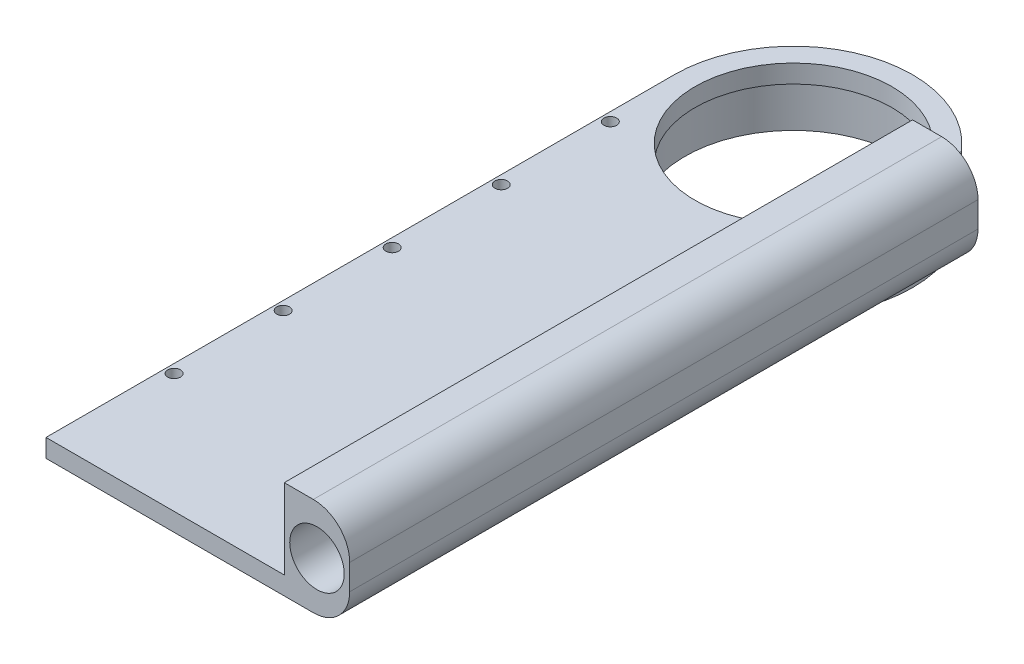
from build123d import *

# Parameters (mm, degrees)
SKETCH1_R            = 2.75
SKETCH1_R_2          = 1.25
SKETCH1_R_3          = 1.75
SKETCH1_R_4          = 4.5
BOSS_EXTRUDE10_DEPTH = 5
SKETCH1_16_R         = 1.25
BOSS_EXTRUDE11_DEPTH = 5
SKETCH3_R            = 1.75
CUT_EXTRUDE5_DEPTH   = 17
CUT_EXTRUDE7_DEPTH   = 10
SKETCH1_18_R         = 4.5
SKETCH1_18_R_2       = 1.75
BOSS_EXTRUDE12_DEPTH = 5
SKETCH10_R           = 32.76798012
SKETCH10_R_2         = 29.85
BOSS_EXTRUDE13_DEPTH = 13
SKETCH11_R           = 27.095
CUT_EXTRUDE8_DEPTH   = 13
BOSS_EXTRUDE14_DEPTH = 3
SKETCH13_W           = 12
SKETCH13_H           = 4
BOSS_EXTRUDE15_DEPTH = 25
SKETCH14_R           = 1.25
CUT_EXTRUDE9_DEPTH   = 25
FILLET1_R            = 2.5
SKETCH18_W           = 172.850535033
SKETCH18_H           = 5
BOSS_EXTRUDE18_DEPTH = 18
SKETCH19_W           = 18
SKETCH19_H           = 172.850535033
BOSS_EXTRUDE19_DEPTH = 22
SKETCH20_R           = 7.5
CUT_EXTRUDE11_DEPTH  = 208
FILLET3_R            = 10


with BuildPart() as part:
    # Sketch1 → Boss-Extrude10 (new body)
    with BuildSketch(Plane(origin=(0, 0, 0), x_dir=(1, 0, 0), z_dir=(0, 1, 0))):
        with BuildLine():
            Line((-32.774, 177.619546288), (-32.774, -22.380453712))
            ThreePointArc((-32.774, -22.380453712), (0, -55.154453712), (32.774, -22.380453712))
            Line((32.774, -22.380453712), (32.774, 177.619546288))
            ThreePointArc((32.774, 177.619546288), (0, 210.393546288), (-32.774, 177.619546288))
        make_face()
        with Locations((-11.258330249, -28.880453712)):
            Circle(SKETCH1_R, mode=Mode.SUBTRACT)
        with Locations((-11.258330249, -15.880453712)):
            Circle(SKETCH1_R, mode=Mode.SUBTRACT)
        with Locations((-6.733414, 27.619546288)):
            Circle(SKETCH1_R_2, mode=Mode.SUBTRACT)
        with Locations((-6.733414, 37.119546288)):
            Circle(SKETCH1_R_2, mode=Mode.SUBTRACT)
        with Locations((-14.032659813, 67.637846288)):
            Circle(SKETCH1_R_3, mode=Mode.SUBTRACT)
        with Locations((0, -35.380453712)):
            Circle(SKETCH1_R, mode=Mode.SUBTRACT)
        with Locations((11.258330249, -28.880453712)):
            Circle(SKETCH1_R, mode=Mode.SUBTRACT)
        with Locations((0, -9.380453712)):
            Circle(SKETCH1_R, mode=Mode.SUBTRACT)
        with Locations((11.258330249, -15.880453712)):
            Circle(SKETCH1_R, mode=Mode.SUBTRACT)
        with Locations((0, 53.605186475)):
            Circle(SKETCH1_R_3, mode=Mode.SUBTRACT)
        with Locations((14.032659813, 67.637846288)):
            Circle(SKETCH1_R_3, mode=Mode.SUBTRACT)
        with Locations((0, 81.6705061)):
            Circle(SKETCH1_R_3, mode=Mode.SUBTRACT)
        with Locations((0, 177.619546288)):
            Circle(SKETCH1_R_4, mode=Mode.SUBTRACT)
        with Locations((0, 67.637846288)):
            Circle(SKETCH1_R_4, mode=Mode.SUBTRACT)
    extrude(amount=-BOSS_EXTRUDE10_DEPTH)

    # Sketch1_16 → Boss-Extrude11 (add)
    with BuildSketch(Plane(origin=(0, 0, 0), x_dir=(1, 0, 0), z_dir=(0, 1, 0))):
        with Locations((-6.733414, 37.119546288)):
            Circle(SKETCH1_16_R)
        with Locations((-6.733414, 27.619546288)):
            Circle(SKETCH1_16_R)
    extrude(amount=-BOSS_EXTRUDE11_DEPTH)

    # Sketch3 → Cut-Extrude5 (cut)
    with BuildSketch(Plane.XZ.offset(5)):
        with Locations((15, -102.056321071)):
            Circle(SKETCH3_R)
        with Locations((-30.384, -67.619546288)):
            Circle(SKETCH3_R)
        with Locations((-30.384, -37.619546288)):
            Circle(SKETCH3_R)
        with Locations((-30.384, -97.619546288)):
            Circle(SKETCH3_R)
        with Locations((-30.384, -127.619546288)):
            Circle(SKETCH3_R)
        with Locations((-30.384, -157.619546288)):
            Circle(SKETCH3_R)
        with Locations((30.384, -157.619546288)):
            Circle(SKETCH3_R)
        with Locations((30.384, -127.619546288)):
            Circle(SKETCH3_R)
        with Locations((30.384, -97.619546288)):
            Circle(SKETCH3_R)
        with Locations((30.384, -67.619546288)):
            Circle(SKETCH3_R)
        with Locations((30.384, -37.619546288)):
            Circle(SKETCH3_R)
    extrude(amount=-CUT_EXTRUDE5_DEPTH, mode=Mode.SUBTRACT)

    # Sketch2 → Cut-Extrude7 (cut)
    with BuildSketch(Plane.XZ):
        with BuildLine():
            Line((-32.774000001, -4.769011255), (32.774000001, -4.769011255))
            Line((32.774000001, -4.769011255), (32.774000001, 22.380453712))
            ThreePointArc((32.774000001, 22.380453712), (0, 55.154453713), (-32.774000001, 22.380453712))
            Line((-32.774000001, 22.380453712), (-32.774000001, -4.769011255))
        make_face()
    extrude(amount=CUT_EXTRUDE7_DEPTH, mode=Mode.SUBTRACT)

    # Sketch1_18 → Boss-Extrude12 (add)
    with BuildSketch(Plane(origin=(0, 0, 0), x_dir=(1, 0, 0), z_dir=(0, 1, 0))):
        with Locations((0, 67.637846288)):
            Circle(SKETCH1_18_R)
        with Locations((0, 53.605186475)):
            Circle(SKETCH1_18_R_2)
        with Locations((-14.032659813, 67.637846288)):
            Circle(SKETCH1_18_R_2)
        with Locations((0, 81.6705061)):
            Circle(SKETCH1_18_R_2)
        with Locations((14.032659813, 67.637846288)):
            Circle(SKETCH1_18_R_2)
    extrude(amount=-BOSS_EXTRUDE12_DEPTH)

    # Sketch10 → Boss-Extrude13 (add)
    with BuildSketch(Plane.XZ.offset(5)):
        with Locations((0, -177.619546288)):
            Circle(SKETCH10_R)
        with Locations((0, -177.619546288)):
            Circle(SKETCH10_R_2, mode=Mode.SUBTRACT)
    extrude(amount=BOSS_EXTRUDE13_DEPTH)

    # Sketch11 → Cut-Extrude8 (cut)
    with BuildSketch(Plane.XZ.offset(5)):
        with Locations((0, -177.619546288)):
            Circle(SKETCH11_R)
    extrude(amount=-CUT_EXTRUDE8_DEPTH, mode=Mode.SUBTRACT)

    # Sketch5 → Boss-Extrude14 (add)
    with BuildSketch(Plane.XZ.offset(5)):
        Polygon((-7.824000001, -54.439091018), (-7.824000001, -50.294800153), (11.225999999, -50.294800153), (11.225999999, -52.737107845), (-5.625923078, -52.737107845), (-5.625923078, -55.667877076), align=None)
        Polygon((-7.824000001, -77.404415537), (-7.824000001, -74.946843422), (6.78786899, -68.867786932), (-7.824000001, -62.792546547), (-7.824000001, -60.308261691), (11.225999999, -68.478544143), (11.225999999, -69.260845826), align=None)
        Polygon((11.225999999, -103.048646307), (-7.824000001, -103.048646307), (-7.824000001, -102.144229239), (6.650489182, -90.592877076), (-7.824000001, -90.592877076), (-7.824000001, -88.150569384), (11.225999999, -88.150569384), (11.225999999, -89.150389095), (-3.210328126, -100.606338614), (11.225999999, -100.606338614), align=None)
        with BuildLine():
            Line((-7.824000001, -110.131338614), (-7.824000001, -107.689030922))
            Line((-7.824000001, -107.689030922), (4.963770432, -107.689030922))
            add(Edge.make_bspline(
                [(4.963770432, -107.689030922), (5.195284298, -107.690885051), (5.64058499, -107.694451338), (6.282127583, -107.710622767), (6.869902619, -107.750196634), (7.404321802, -107.799507581), (7.886610584, -107.856591103), (8.313879678, -107.93850968), (8.689949893, -108.026630447), (9.116491069, -108.169153007), (9.595339884, -108.393934907), (10.111712604, -108.751940741), (10.571673312, -109.196571131), (10.907530608, -109.628416016), (11.13794534, -110.012545465), (11.297510075, -110.317623544), (11.424793799, -110.643597173), (11.533834774, -110.983321068), (11.610882457, -111.340471014), (11.674764914, -111.711796449), (11.707736212, -112.10111909), (11.712193771, -112.36625392), (11.714461538, -112.501140297)],
                knots=[0, 0, 0, 0, 1.452629871, 2.794031722, 4.025694375, 5.147841271, 6.161522649, 7.070971626, 7.876222586, 8.582890533, 9.889534196, 11.180212824, 12.506716644, 13.889181747, 14.598189363, 15.315636514, 16.046279605, 16.790911698, 17.551832231, 18.336450274, 19.153675152, 20, 20, 20, 20], degree=3))
            add(Edge.make_bspline(
                [(11.714461538, -112.501140297), (11.709715065, -112.690996015), (11.700270364, -113.068777754), (11.611584234, -113.632488096), (11.470780234, -114.18810384), (11.271570837, -114.74809611), (10.996525721, -115.32564021), (10.608190367, -115.923011587), (10.131794371, -116.566713359), (9.758962639, -116.990402865), (9.562177884, -117.214030922)],
                knots=[0, 0, 0, 0, 0.856972921, 1.705235559, 2.570545082, 3.44278821, 4.385852251, 5.452194716, 6.655239899, 8, 8, 8, 8], degree=3))
            Line((9.562177884, -117.214030922), (7.80676923, -116.004325393))
            add(Edge.make_bspline(
                [(7.80676923, -116.004325393), (7.894907738, -115.863356861), (8.065044953, -115.59123978), (8.304537659, -115.195035974), (8.521847451, -114.828568699), (8.718040268, -114.494300424), (8.884251955, -114.186630498), (9.035266134, -113.914342494), (9.157620565, -113.667523035), (9.230416916, -113.512520303), (9.264521634, -113.439902316)],
                knots=[0, 0, 0, 0, 1.35182785, 2.609486248, 3.764263372, 4.816267098, 5.760612529, 6.607550145, 7.347644362, 8, 8, 8, 8], degree=3))
            add(Edge.make_bspline(
                [(9.264521634, -113.439902316), (9.30296182, -113.348904612), (9.376646938, -113.174473182), (9.457997196, -112.91437331), (9.506417053, -112.668323997), (9.513151386, -112.508961908), (9.516384615, -112.432450393)],
                knots=[0, 0, 0, 0, 1.132993667, 2.17180979, 3.122265503, 4, 4, 4, 4], degree=3))
            add(Edge.make_bspline(
                [(9.516384615, -112.432450393), (9.511267111, -112.318803952), (9.501130651, -112.093699551), (9.419283826, -111.764584671), (9.277522501, -111.45621453), (9.090739979, -111.16641845), (8.859379113, -110.901782723), (8.578900769, -110.678865607), (8.260942683, -110.493691853), (7.958995713, -110.380505827), (7.682179611, -110.302721603), (7.423123036, -110.262354362), (7.119487359, -110.218405126), (6.769344681, -110.184594649), (6.372022147, -110.164686683), (5.928147668, -110.144130246), (5.438290975, -110.133455838), (5.096065936, -110.13206328), (4.917977163, -110.131338614)],
                knots=[0, 0, 0, 0, 0.938055486, 1.858046901, 2.779836698, 3.729995872, 4.697713164, 5.669188152, 6.676648582, 7.724504959, 8.32352458, 9.04907482, 9.887175513, 10.858480013, 11.953077028, 13.173078688, 14.528912581, 16, 16, 16, 16], degree=3))
            Line((4.917977163, -110.131338614), (-7.824000001, -110.131338614))
        make_face()
    extrude(amount=BOSS_EXTRUDE14_DEPTH)

    # Sketch13 → Boss-Extrude15 (add)
    with BuildSketch(Plane.XZ.offset(5)):
        with Locations((0.000999999, -123.10114465)):
            Rectangle(SKETCH13_W, SKETCH13_H)
    extrude(amount=BOSS_EXTRUDE15_DEPTH)

    # Sketch14 → Cut-Extrude9 (cut)
    with BuildSketch(Plane(origin=(0, 0, -125.10114465), x_dir=(-1, 0, 0), z_dir=(0, 0, -1))):
        with Locations((0, -22.5)):
            Circle(SKETCH14_R)
        with Locations((0, -13)):
            Circle(SKETCH14_R)
    extrude(amount=-CUT_EXTRUDE9_DEPTH, mode=Mode.SUBTRACT)

    # Fillet1
    fillet1_edges = [part.edges().sort_by_distance(p)[0] for p in [
        (6.000999999, -30, -123.10114465),
        (-5.999000001, -30, -123.10114465),
        (-5.999000001, -5, -123.10114465),
        (6.000999999, -5, -123.10114465),
    ]]
    fillet(fillet1_edges, radius=FILLET1_R)

    # Sketch18 → Boss-Extrude18 (add)
    with BuildSketch(Plane(origin=(32.774, 0, 0), x_dir=(0, 0, -1), z_dir=(1, 0, 0))):
        with Locations((91.194278772, -2.5)):
            Rectangle(SKETCH18_W, SKETCH18_H)
    extrude(amount=BOSS_EXTRUDE18_DEPTH)

    # Sketch19 → Boss-Extrude19 (add)
    with BuildSketch(Plane(origin=(0, 0, 0), x_dir=(1, 0, 0), z_dir=(0, 1, 0))):
        with Locations((41.774, 91.194278772)):
            Rectangle(SKETCH19_W, SKETCH19_H)
    extrude(amount=BOSS_EXTRUDE19_DEPTH)

    # Sketch20 → Cut-Extrude11 (cut)
    with BuildSketch(Plane(origin=(0, 0, -177.619546288), x_dir=(-1, 0, 0), z_dir=(0, 0, -1))):
        with Locations((-41.774, 8.5)):
            Circle(SKETCH20_R)
    extrude(amount=-CUT_EXTRUDE11_DEPTH, mode=Mode.SUBTRACT)

    # Fillet3
    fillet3_edges = [part.edges().sort_by_distance(p)[0] for p in [
        (50.774, -5, -91.194278771),
        (50.774, 22, -91.194278771),
    ]]
    fillet(fillet3_edges, radius=FILLET3_R)


solid = part.part
